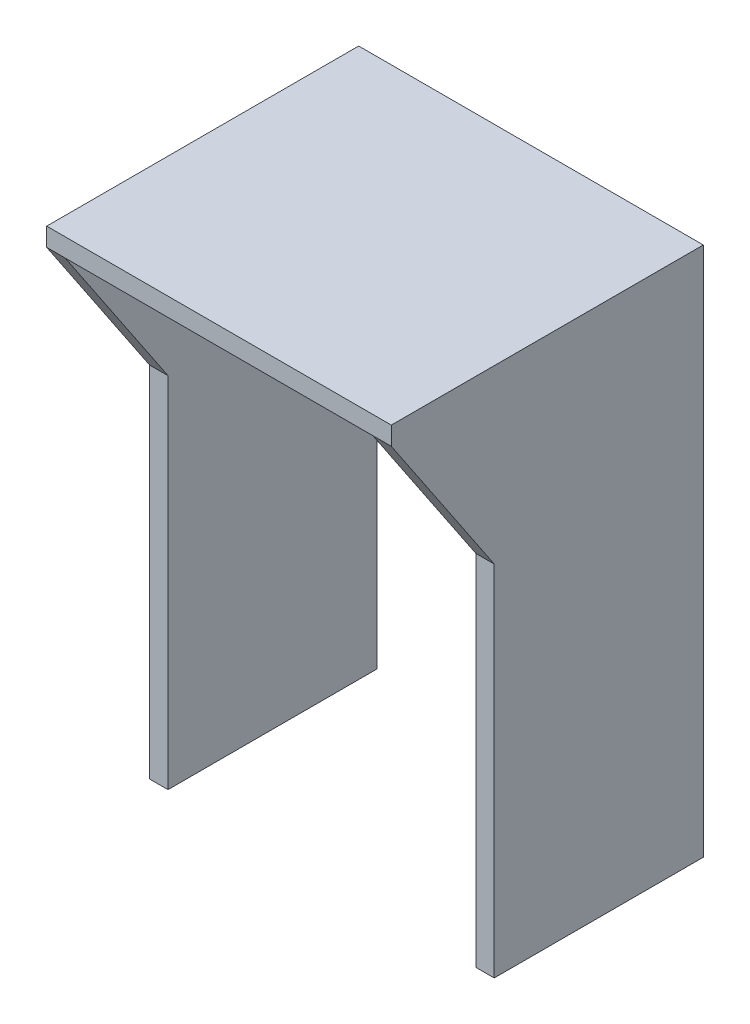
from build123d import *

# Parameters (mm, degrees)
BOSS_EXTRUDE1_DEPTH = 41.2
SKETCH4_W           = 36.8
SKETCH4_H           = 61.2
CUT_EXTRUDE1_DEPTH  = 10000


with BuildPart() as part:
    # Sketch2 → Boss-Extrude1 (new body)
    with BuildSketch(Plane(origin=(0, 0, 0), x_dir=(0, 0, -1), z_dir=(1, 0, 0))):
        Polygon((0, 0), (-25, 0), (-25, 42.867109497), (-37.3, 61.2), (-37.3, 63.4), (0, 63.4), align=None)
    extrude(amount=BOSS_EXTRUDE1_DEPTH)

    # Sketch4 → Cut-Extrude1 (cut)
    with BuildSketch(Plane.XY):
        with Locations((20.6, 30.6)):
            Rectangle(SKETCH4_W, SKETCH4_H)
    extrude(amount=CUT_EXTRUDE1_DEPTH, mode=Mode.SUBTRACT)


solid = part.part
